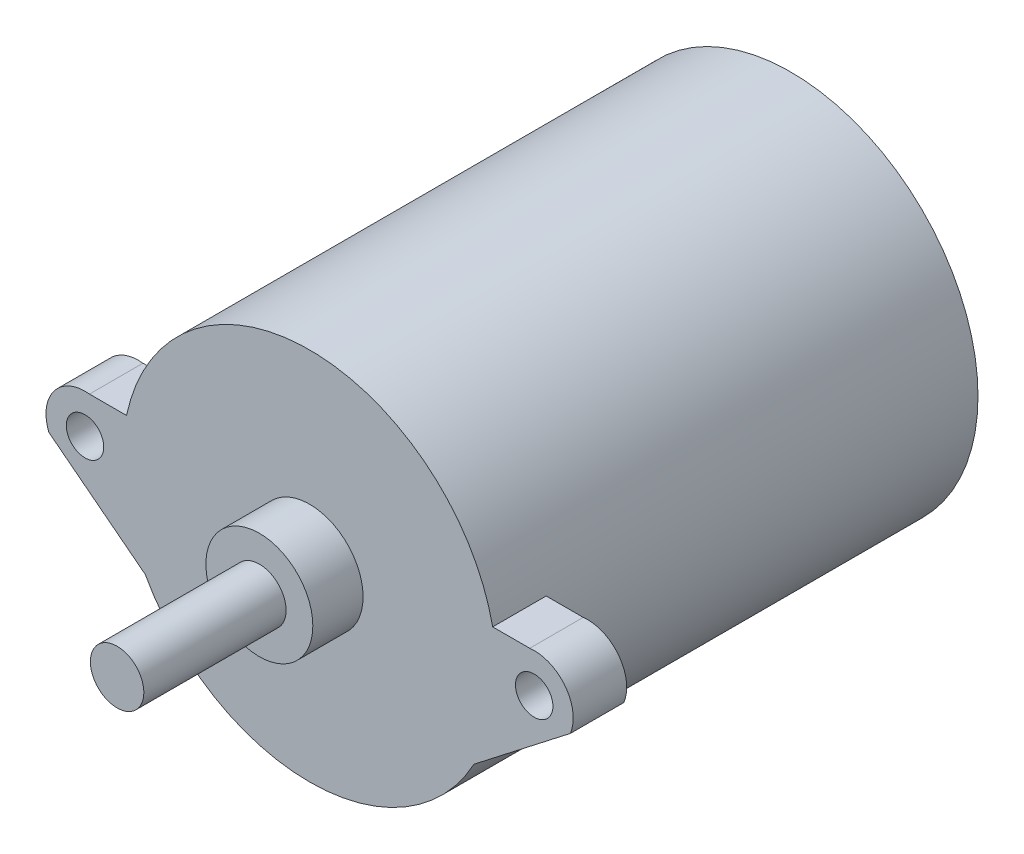
from build123d import *

# Parameters (mm, degrees)
SKETCH1_R           = 17.5
BOSS_EXTRUDE1_DEPTH = 45
SKETCH7_R           = 1.75
BOSS_EXTRUDE2_DEPTH = 5


with BuildPart() as part:
    # Sketch1 → Boss-Extrude1 (new body)
    with BuildSketch(Plane.XY.offset(33.02)):
        Circle(SKETCH1_R)
    extrude(amount=-BOSS_EXTRUDE1_DEPTH)

    # Sketch6 → Revolve5 (revolve)
    with BuildSketch(Plane(origin=(0, 0, 0), x_dir=(1, 0, 0), z_dir=(0, 1, 0))):
        Polygon((5, -33.02), (0, -33.02), (0, -51.02), (2.5, -51.02), (2.5, -37.72), (5, -37.72), align=None)
    revolve(axis=Axis((0, 0, 33.02), (0, 0, 1)))

    # Sketch7 → Boss-Extrude2 (add)
    with BuildSketch(Plane.XY.offset(33.02)):
        with BuildLine():
            Line((17.12018182, 3.626206621), (20.583916427, 3.626206621))
            ThreePointArc((20.583916427, 3.626206621), (23.906641712, 2.207698792), (24.381596036, -1.373793379))
            Line((24.381596036, -1.373793379), (15.366508532, -8.373793379))
            Line((15.366508532, -8.373793379), (17.12018182, 3.626206621))
        make_face()
        with Locations((21, 0)):
            Circle(SKETCH7_R, mode=Mode.SUBTRACT)
        with BuildLine():
            Line((-17.12018182, 3.626206621), (-20.583916427, 3.626206621))
            ThreePointArc((-20.583916427, 3.626206621), (-23.906641712, 2.207698792), (-24.381596036, -1.373793379))
            Line((-24.381596036, -1.373793379), (-15.366508532, -8.373793379))
            Line((-15.366508532, -8.373793379), (-17.12018182, 3.626206621))
        make_face()
        with Locations((-21, 0)):
            Circle(SKETCH7_R, mode=Mode.SUBTRACT)
    extrude(amount=-BOSS_EXTRUDE2_DEPTH)


solid = part.part
